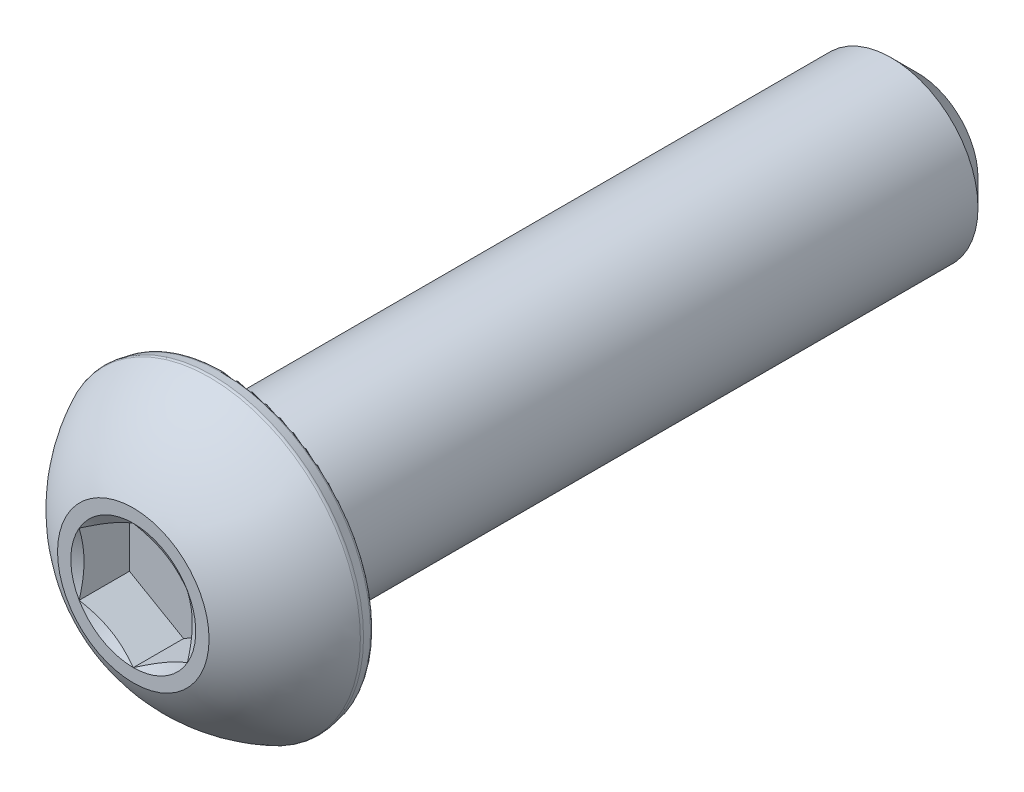
from build123d import *

# Parameters (mm, degrees)
CUT_EXTRUDE1_DEPTH = 1.84404
SKETCH5_R          = 2.291358881
CUT_EXTRUDE2_DEPTH = 1.84404
CUT_EXTRUDE2_DRAFT = -60
FILLET1_R          = 0.16764


with BuildPart() as part:
    # Sketch3 → Revolve1 (revolve)
    with BuildSketch(Plane(origin=(0, 0, 0), x_dir=(0, 0, -1), z_dir=(1, 0, 0))):
        with BuildLine():
            Line((-14.3764, 0), (-14.3764, 2.778125))
            ThreePointArc((-14.3764, 2.778125), (-13.182024687, 4.401074199), (-11.52652, 5.5499))
            Line((-11.52652, 5.5499), (-11.0236, 5.461221635))
            Line((-11.0236, 5.461221635), (-11.0236, 3.175))
            Line((-11.0236, 3.175), (13.4239, 3.175))
            Line((13.4239, 3.175), (14.3764, 2.2225))
            Line((14.3764, 2.2225), (14.3764, 0))
            Line((14.3764, 0), (-14.3764, 0))
        make_face()
    revolve(axis=Axis((0, 0, 14.3764), (0, 0, -1)))

    # Sketch4 → Cut-Extrude1 (cut)
    with BuildSketch(Plane.XY.offset(14.3764)):
        Polygon((-1.984375, -1.14567944), (0, -2.291358881), (1.984375, -1.14567944), (1.984375, 1.14567944), (0, 2.291358881), (-1.984375, 1.14567944), align=None)
    extrude(amount=-CUT_EXTRUDE1_DEPTH, mode=Mode.SUBTRACT)


with BuildPart() as cut_extrude2_tool:
    # Sketch5 → Cut-Extrude2 (with draft: the straight prism first)
    with BuildSketch(Plane.XY.offset(14.3764)):
        Circle(SKETCH5_R)
    extrude(amount=-CUT_EXTRUDE2_DEPTH)
    # Cut-Extrude2: the draft: its side faces are tilted about the plane it starts from
    cut_extrude2_sides = [cut_extrude2_tool.faces().sort_by_distance(p)[0] for p in [
        (-2.291358881, 0, 13.45438),
    ]]
    draft(cut_extrude2_sides, Plane.XY.offset(14.3764), CUT_EXTRUDE2_DRAFT)


with BuildPart() as part_1:
    add(part.part)

    # Cut-Extrude2: cut by cut_extrude2_tool
    add(cut_extrude2_tool.part, mode=Mode.SUBTRACT)

    # Fillet1
    fillet1_edges = [part_1.edges().sort_by_distance(p)[0] for p in [
        (0, -5.461221635, 11.0236),
        (0, -5.5499, 11.52652),
    ]]
    fillet(fillet1_edges, radius=FILLET1_R)


solid = part_1.part
